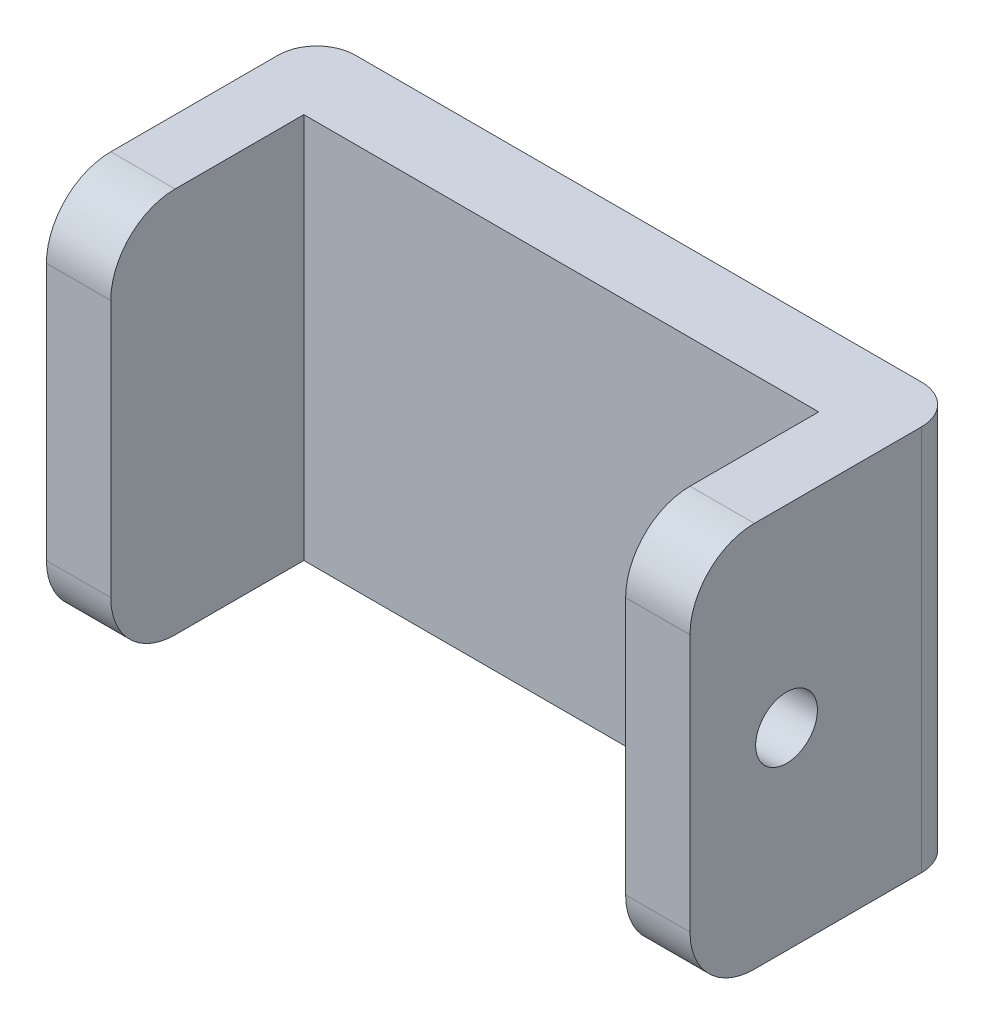
from build123d import *

# Parameters (mm, degrees)
SKETCH1_W           = 50
SKETCH1_H           = 30
BOSS_EXTRUDE1_DEPTH = 6
SKETCH3_W           = 5
SKETCH3_H           = 30
BOSS_EXTRUDE2_DEPTH = 15
SKETCH4_R           = 2.4
CUT_EXTRUDE1_DEPTH  = 5
FILLET2_R           = 3
FILLET3_R           = 5


with BuildPart() as part:
    # Sketch1 → Boss-Extrude1 (new body)
    with BuildSketch(Plane.XY):
        with Locations((-261.5, -48)):
            Rectangle(SKETCH1_W, SKETCH1_H)
    extrude(amount=BOSS_EXTRUDE1_DEPTH)

    # Sketch3 → Boss-Extrude2 (add)
    with BuildSketch(Plane.XY.offset(6)):
        with Locations((-239, -48)):
            Rectangle(SKETCH3_W, SKETCH3_H)
        with Locations((-284, -48)):
            Rectangle(SKETCH3_W, SKETCH3_H)
    extrude(amount=BOSS_EXTRUDE2_DEPTH)

    # Sketch4 → Cut-Extrude1 (cut)
    with BuildSketch(Plane(origin=(-236.5, 0, 0), x_dir=(0, 0, -1), z_dir=(1, 0, 0))):
        with Locations((-13.5, -48)):
            Circle(SKETCH4_R)
    extrude(amount=-CUT_EXTRUDE1_DEPTH, mode=Mode.SUBTRACT)

    # Fillet2
    fillet2_edges = [part.edges().sort_by_distance(p)[0] for p in [
        (-236.5, -48, 0),
        (-286.5, -48, 0),
    ]]
    fillet(fillet2_edges, radius=FILLET2_R)

    # Fillet3
    fillet3_edges = [part.edges().sort_by_distance(p)[0] for p in [
        (-239, -33, 21),
        (-239, -63, 21),
        (-284, -63, 21),
        (-284, -33, 21),
    ]]
    fillet(fillet3_edges, radius=FILLET3_R)


solid = part.part
